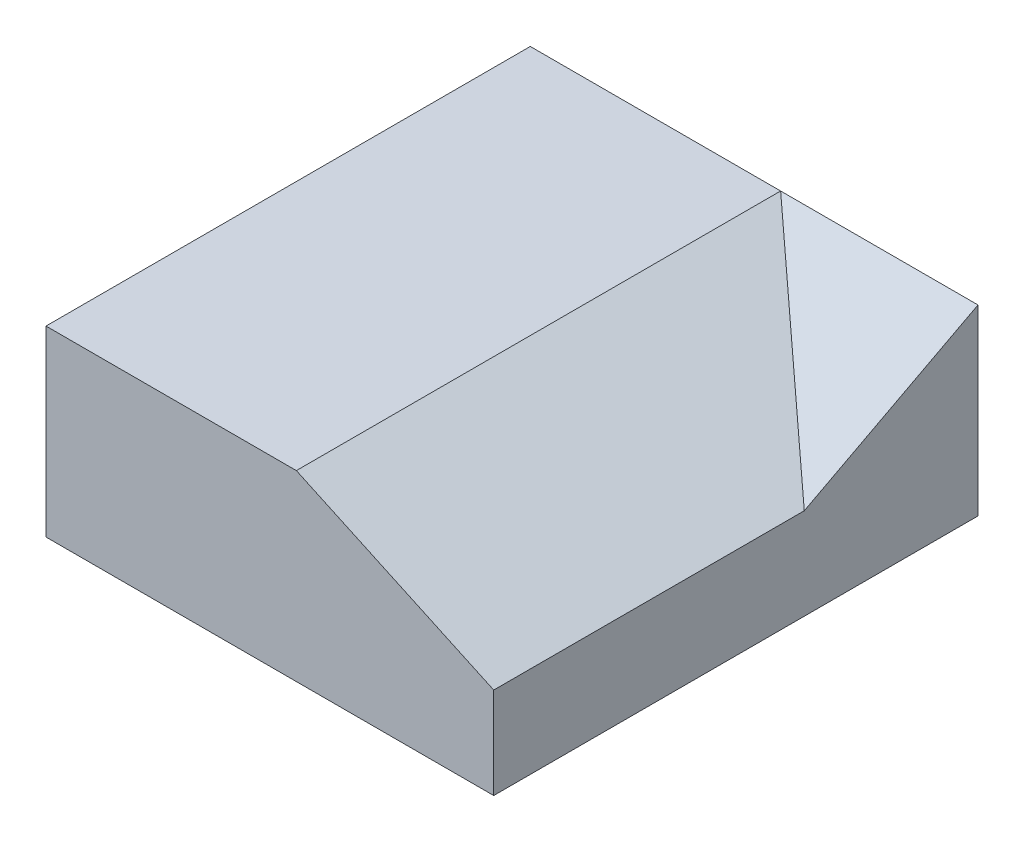
from build123d import *

# Parameters (mm, degrees)
SKETCH1_W           = 49
SKETCH1_H           = 53
BOSS_EXTRUDE1_DEPTH = 20
SKETCH3_W           = 45
SKETCH3_H           = 49
CUT_EXTRUDE1_DEPTH  = 18
CUT_EXTRUDE2_DEPTH  = 34
CUT_EXTRUDE3_DEPTH  = 21.6
BOSS_EXTRUDE4_DEPTH = 53
BOSS_EXTRUDE5_DEPTH = 21.6
CUT_EXTRUDE4_DEPTH  = 18
CUT_EXTRUDE5_DEPTH  = 18
BOSS_EXTRUDE6_DEPTH = 18
SKETCH16_R          = 1
BOSS_EXTRUDE7_DEPTH = 18
SKETCH17_W          = 13.959273649
SKETCH17_H          = 5.98254585
CUT_EXTRUDE7_DEPTH  = 2


with BuildPart() as part:
    # Sketch1 → Boss-Extrude1 (new body)
    with BuildSketch(Plane(origin=(0, 0, 0), x_dir=(1, 0, 0), z_dir=(0, 1, 0))):
        with Locations((-6.199798715, -1.247894993)):
            Rectangle(SKETCH1_W, SKETCH1_H)
    extrude(amount=BOSS_EXTRUDE1_DEPTH)

    # Sketch3 → Cut-Extrude1 (cut)
    with BuildSketch(Plane.XZ):
        with Locations((-6.199798715, 1.247894993)):
            Rectangle(SKETCH3_W, SKETCH3_H)
    extrude(amount=-CUT_EXTRUDE1_DEPTH, mode=Mode.SUBTRACT)

    # Sketch4 → Cut-Extrude2 (cut)
    with BuildSketch(Plane.XY.offset(27.747894993)):
        Polygon((18.300201285, 20), (-3.299798715, 20), (18.300201285, 10), align=None)
    extrude(amount=-CUT_EXTRUDE2_DEPTH, mode=Mode.SUBTRACT)

    # Sketch6 → Cut-Extrude3 (cut)
    with BuildSketch(Plane(origin=(18.300201285, 0, 0), x_dir=(0, 0, -1), z_dir=(1, 0, 0))):
        Polygon((6.252105007, 10.006685103), (25.252105007, 20), (6.252105007, 20), align=None)
    extrude(amount=-CUT_EXTRUDE3_DEPTH, mode=Mode.SUBTRACT)

    # Sketch8 → Boss-Extrude4 (add)
    with BuildSketch(Plane.XY.offset(27.747894993)):
        Polygon((-1.339670196, 17.990564534), (-3.299798715, 19), (-3.299798715, 20), (-1.339670196, 19.092533093), (16.300201285, 10.925925926), (18.300201285, 10), (18.300201285, 8.793988713), (16.300201285, 9.823957367), align=None)
    extrude(amount=-BOSS_EXTRUDE4_DEPTH)

    # Sketch11 → Boss-Extrude5 (add)
    with BuildSketch(Plane(origin=(18.300201285, 0, 0), x_dir=(0, 0, -1), z_dir=(1, 0, 0))):
        Polygon((25.252105007, 20), (6.252105007, 10.006685103), (8.400320892, 10.006685103), (25.252105007, 18.870115905), align=None)
    extrude(amount=-BOSS_EXTRUDE5_DEPTH)

    # Sketch12 → Cut-Extrude4 (cut)
    with BuildSketch(Plane.XY.offset(-23.252105007)):
        Polygon((-3.299798715, 17.818188021), (-3.299798715, 10.006685103), (15.905509375, 10.006685103), (-0.967336928, 17.818188021), align=None)
    extrude(amount=CUT_EXTRUDE4_DEPTH, mode=Mode.SUBTRACT)

    # Sketch13 → Cut-Extrude5 (cut)
    with BuildSketch(Plane.ZY.offset(-16.300201285)):
        Polygon((-23.252105007, 17.818188021), (-23.252105007, 9.823957367), (-19.905888942, 9.823957367), (-8.052905944, 9.823957367), (-19.905888942, 16.058199029), align=None)
    extrude(amount=CUT_EXTRUDE5_DEPTH, mode=Mode.SUBTRACT)

    # Sketch15 → Boss-Extrude6 (add)
    with BuildSketch(Plane.XY.offset(-23.252105007)):
        Polygon((-3.299798715, 19), (-3.299798715, 18), (-1.339670196, 17.990564534), align=None)
    extrude(amount=BOSS_EXTRUDE6_DEPTH)

    # Sketch16 → Boss-Extrude7 (add)
    with BuildSketch(Plane.XZ.offset(-18)):
        with Locations((-26.249798715, 23.297894993)):
            Circle(SKETCH16_R)
        with Locations((-5.749798715, 23.297894993)):
            Circle(SKETCH16_R)
        with Locations((-26.249798715, -20.802105007)):
            Circle(SKETCH16_R)
        with Locations((-5.749798715, -20.802105007)):
            Circle(SKETCH16_R)
    extrude(amount=BOSS_EXTRUDE7_DEPTH)

    # Sketch17 → Cut-Extrude7 (cut)
    with BuildSketch(Plane(origin=(0, 0, -25.252105007), x_dir=(-1, 0, 0), z_dir=(0, 0, -1))):
        Polygon((14.456637368, 16.607010477), (12.63034375, 16.059122392), (12.63034375, 14.207010477), (20.63034375, 14.207010477), (20.63034375, 16.059122392), (18.456257111, 16.607010477), align=None)
        with Locations((-5.611259633, 11.265470537)):
            Rectangle(SKETCH17_W, SKETCH17_H)
    extrude(amount=-CUT_EXTRUDE7_DEPTH, mode=Mode.SUBTRACT)


solid = part.part
